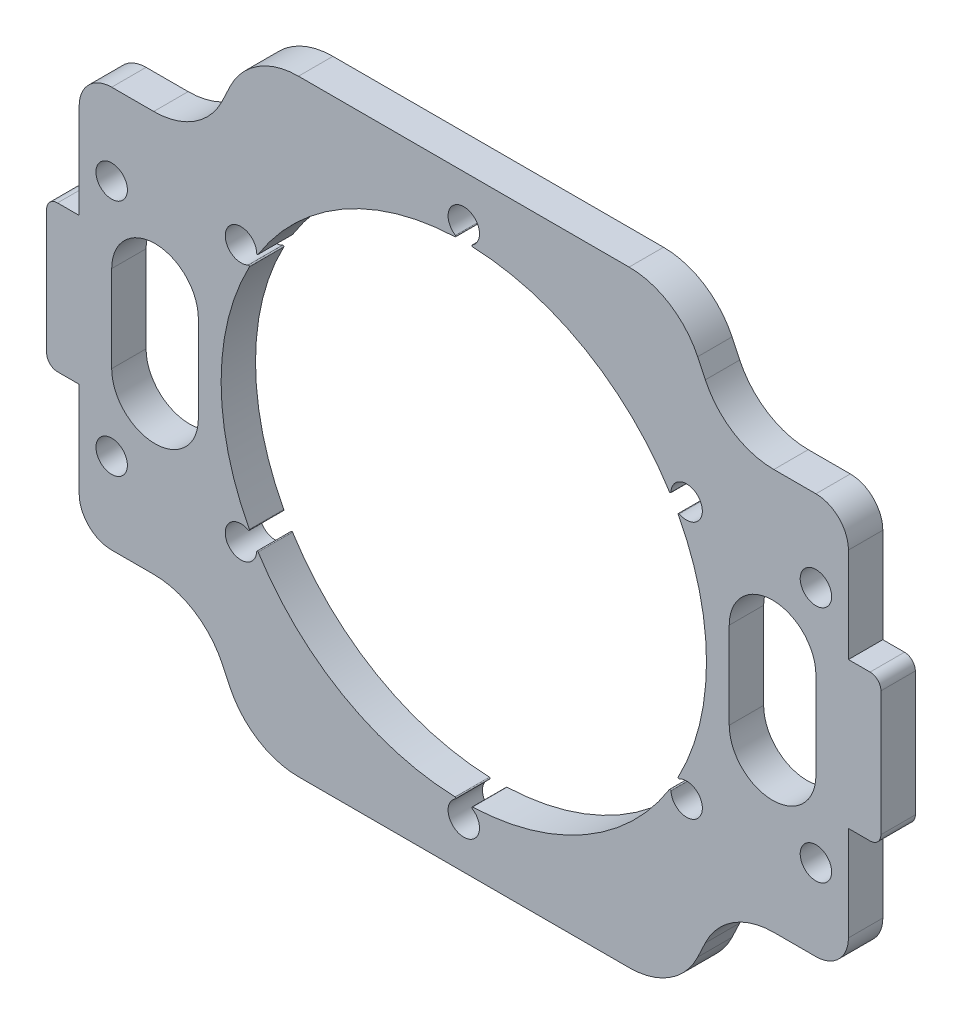
from build123d import *

# Parameters (mm, degrees)
SKETCH1_W               = 71
SKETCH1_H               = 56
SKETCH1_R               = 22.4
BOSS_EXTRUDE1_DEPTH     = 3.175
SKETCH3_R               = 1.45
CUT_EXTRUDE2_DEPTH      = 4.175
CUT_EXTRUDE7_DEPTH      = 4.175
SKETCH12_R              = 1.45
CUT_EXTRUDE8_DEPTH      = 1
CUT_EXTRUDE8_DEPTH_BACK = 4.175
SKETCH15_W              = 3
SKETCH15_H              = 13.5
BOSS_EXTRUDE3_DEPTH     = 3.175
FILLET3_R               = 7
FILLET4_R               = 3
CUT_EXTRUDE6_DEPTH      = 4.175
FILLET5_R               = 1
FILLET6_R               = 0.075


with BuildPart() as part:
    # Sketch1 → Boss-Extrude1 (new body)
    with BuildSketch(Plane.XY):
        Rectangle(SKETCH1_W, SKETCH1_H)
        Circle(SKETCH1_R, mode=Mode.SUBTRACT)
    extrude(amount=BOSS_EXTRUDE1_DEPTH)

    # Sketch3 → Cut-Extrude2 (cut, through all)
    with BuildSketch(Plane.XY.offset(3.175)):
        with Locations((0, 23.75)):
            Circle(SKETCH3_R)
        with Locations((20.56810334, 11.875)):
            Circle(SKETCH3_R)
        with Locations((20.56810334, -11.875)):
            Circle(SKETCH3_R)
        with Locations((0, -23.75)):
            Circle(SKETCH3_R)
        with Locations((-20.56810334, -11.875)):
            Circle(SKETCH3_R)
        with Locations((-20.56810334, 11.875)):
            Circle(SKETCH3_R)
    extrude(amount=-CUT_EXTRUDE2_DEPTH, mode=Mode.SUBTRACT)

    # Sketch11 → Cut-Extrude7 (cut, through all)
    with BuildSketch(Plane.XY.offset(3.175)):
        Polygon((-24.187984705, 18.5), (-35.5, 18.5), (-35.5, 28), (-19.687984705, 28), align=None)
        Polygon((35.5, 28), (19.687984705, 28), (24.187984705, 18.5), (35.5, 18.5), align=None)
        Polygon((19.687984705, -28), (24.187984705, -18.5), (35.5, -18.5), (35.5, -28), align=None)
        Polygon((-35.5, -28), (-19.687984705, -28), (-24.187984705, -18.5), (-35.5, -18.5), align=None)
    extrude(amount=-CUT_EXTRUDE7_DEPTH, mode=Mode.SUBTRACT)

    # Sketch12 → Cut-Extrude8 (cut, two sides)
    with BuildSketch(Plane.XY.offset(3.175)) as cut_extrude8_sk:
        with Locations((-32.5, 11)):
            Circle(SKETCH12_R)
        with Locations((-32.5, -11)):
            Circle(SKETCH12_R)
        with Locations((32.5, -11)):
            Circle(SKETCH12_R)
        with Locations((32.5, 11)):
            Circle(SKETCH12_R)
    extrude(amount=CUT_EXTRUDE8_DEPTH, mode=Mode.SUBTRACT)
    extrude(cut_extrude8_sk.sketch, amount=-CUT_EXTRUDE8_DEPTH_BACK, mode=Mode.SUBTRACT)

    # Sketch15 → Boss-Extrude3 (add)
    with BuildSketch(Plane(origin=(0, 0, 0), x_dir=(-1, 0, 0), z_dir=(0, 0, -1))):
        with Locations((-37, 0)):
            Rectangle(SKETCH15_W, SKETCH15_H)
        with Locations((37, 0)):
            Rectangle(SKETCH15_W, SKETCH15_H)
    extrude(amount=-BOSS_EXTRUDE3_DEPTH)

    # Fillet3
    fillet3_edges = [part.edges().sort_by_distance(p)[0] for p in [
        (24.187984705, 18.5, 1.5875),
        (19.687984705, 28, 1.5875),
        (-19.687984705, 28, 1.5875),
        (-24.187984705, 18.5, 1.5875),
        (-24.187984705, -18.5, 1.5875),
        (-19.687984705, -28, 1.5875),
        (19.687984705, -28, 1.5875),
        (24.187984705, -18.5, 1.5875),
    ]]
    fillet(fillet3_edges, radius=FILLET3_R)

    # Fillet4
    fillet4_edges = [part.edges().sort_by_distance(p)[0] for p in [
        (35.5, 18.5, 1.5875),
        (-35.5, 18.5, 1.5875),
        (-35.5, -18.5, 1.5875),
        (35.5, -18.5, 1.5875),
    ]]
    fillet(fillet4_edges, radius=FILLET4_R)

    # Sketch10 → Cut-Extrude6 (cut, through all)
    with BuildSketch(Plane.XY.offset(3.175)):
        with BuildLine():
            Line((-24.5, 4), (-24.5, -4))
            ThreePointArc((-24.5, -4), (-28.5, -8), (-32.5, -4))
            Line((-32.5, -4), (-32.5, 4))
            ThreePointArc((-32.5, 4), (-28.5, 8), (-24.5, 4))
        make_face()
        with BuildLine():
            Line((24.5, 4), (24.5, -4))
            ThreePointArc((24.5, -4), (28.5, -8), (32.5, -4))
            Line((32.5, -4), (32.5, 4))
            ThreePointArc((32.5, 4), (28.5, 8), (24.5, 4))
        make_face()
    extrude(amount=-CUT_EXTRUDE6_DEPTH, mode=Mode.SUBTRACT)

    # Fillet5
    fillet5_edges = [part.edges().sort_by_distance(p)[0] for p in [
        (38.5, 6.75, 1.5875),
        (38.5, -6.75, 1.5875),
        (-38.5, -6.75, 1.5875),
        (-38.5, 6.75, 1.5875),
    ]]
    fillet(fillet5_edges, radius=FILLET5_R)

    # Fillet6
    fillet6_edges = [part.edges().sort_by_distance(p)[0] for p in [
        (19.136935336, 11.642066223, 1.5875),
        (19.65079277, 10.75203904, 1.5875),
        (19.65079277, -10.75203904, 1.5875),
        (19.136935336, -11.642066223, 1.5875),
        (0.513857434, -22.394105263, 1.5875),
        (-0.513857434, -22.394105263, 1.5875),
        (-19.136935336, -11.642066223, 1.5875),
        (-19.65079277, -10.75203904, 1.5875),
        (-19.65079277, 10.75203904, 1.5875),
        (-19.136935336, 11.642066223, 1.5875),
        (-0.513857434, 22.394105263, 1.5875),
        (0.513857434, 22.394105263, 1.5875),
    ]]
    fillet(fillet6_edges, radius=FILLET6_R)


solid = part.part
